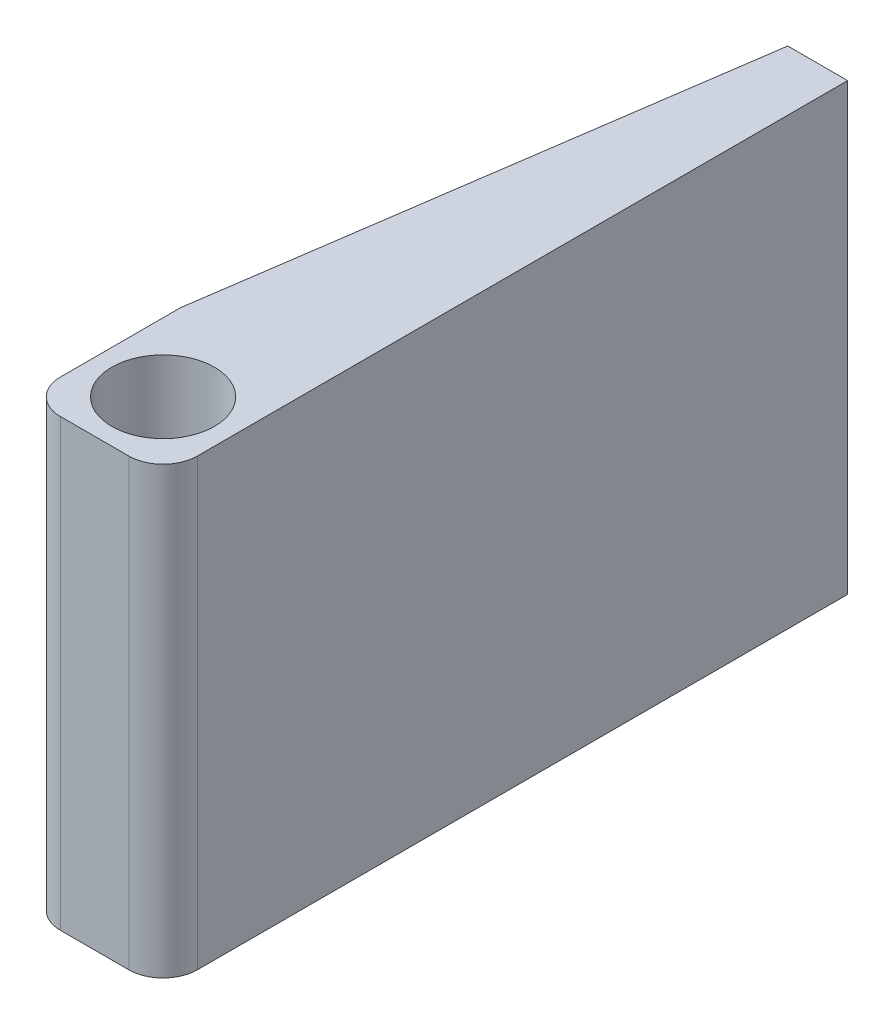
from build123d import *

# Parameters (mm, degrees)
SKETCH2_W           = 508
SKETCH2_H           = 330.2
BOSS_EXTRUDE1_DEPTH = 101.6
SKETCH3_R           = 38.1
CUT_EXTRUDE1_DEPTH  = 331.2
FILLET1_R           = 25.4
CUT_EXTRUDE2_DEPTH  = 331.2
SKETCH5_W           = 23.104275201
SKETCH5_H           = 76.2
CUT_EXTRUDE3_DEPTH  = 50.8


with BuildPart() as part:
    # Sketch2 → Boss-Extrude1 (new body)
    with BuildSketch(Plane(origin=(0, 0, 0), x_dir=(0, 0, -1), z_dir=(1, 0, 0))):
        with Locations((98.635814889, 33.244869215)):
            Rectangle(SKETCH2_W, SKETCH2_H)
    extrude(amount=BOSS_EXTRUDE1_DEPTH)

    # Sketch3 → Cut-Extrude1 (cut, through all)
    with BuildSketch(Plane.XZ.offset(131.855130785)):
        with Locations((50.8, 104.564185111)):
            Circle(SKETCH3_R)
    extrude(amount=-CUT_EXTRUDE1_DEPTH, mode=Mode.SUBTRACT)

    # Fillet1
    fillet1_edges = [part.edges().sort_by_distance(p)[0] for p in [
        (101.6, 33.244869215, 155.364185111),
        (0, 33.244869215, 155.364185111),
    ]]
    fillet(fillet1_edges, radius=FILLET1_R)

    # Sketch4 → Cut-Extrude2 (cut, through all)
    with BuildSketch(Plane.XZ.offset(131.855130785)):
        Polygon((0, 40.959246462), (57.15, -352.635814889), (0, -352.635814889), align=None)
    extrude(amount=-CUT_EXTRUDE2_DEPTH, mode=Mode.SUBTRACT)

    # Sketch5 → Cut-Extrude3 (cut)
    with BuildSketch(Plane(origin=(0, 0, -352.635814889), x_dir=(-1, 0, 0), z_dir=(0, 0, -1))):
        with Locations((-79.8878624, 33.244869215)):
            Rectangle(SKETCH5_W, SKETCH5_H)
    extrude(amount=-CUT_EXTRUDE3_DEPTH, mode=Mode.SUBTRACT)


solid = part.part
